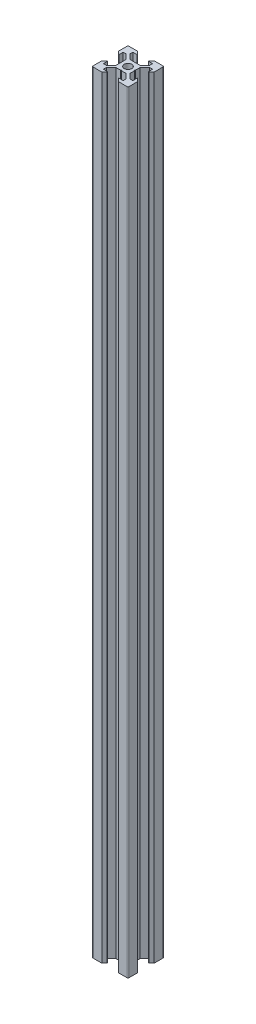
from build123d import *

# Parameters (mm, degrees)
SKETCH1_R           = 2.1
BOSS_EXTRUDE1_DEPTH = 430


with BuildPart() as part:
    # Sketch1 → Boss-Extrude1 (new body)
    with BuildSketch(Plane(origin=(0, -10, 0), x_dir=(1, 0, 0), z_dir=(0, 1, 0))):
        with BuildLine():
            Line((419, 554.5), (419, 549.58))
            Line((419, 549.58), (420.455, 548.125))
            Line((420.455, 548.125), (420.8, 548.125))
            Line((420.8, 548.125), (420.8, 550.5))
            Line((420.8, 550.5), (422.439339828, 550.5))
            Line((422.439339828, 550.5), (425.1, 547.839339828))
            Line((425.1, 547.839339828), (425.1, 545.21))
            Line((425.1, 545.21), (425.31, 545))
            Line((425.31, 545), (425.1, 544.79))
            Line((425.1, 544.79), (425.1, 542.160660172))
            Line((425.1, 542.160660172), (422.439339828, 539.5))
            Line((422.439339828, 539.5), (420.8, 539.5))
            Line((420.8, 539.5), (420.8, 541.875))
            Line((420.8, 541.875), (420.455, 541.875))
            Line((420.455, 541.875), (419, 540.42))
            Line((419, 540.42), (419, 535.5))
            ThreePointArc((419, 535.5), (419.146446609, 535.146446609), (419.5, 535))
            Line((419.5, 535), (424.42, 535))
            Line((424.42, 535), (425.875, 536.455))
            Line((425.875, 536.455), (425.875, 536.8))
            Line((425.875, 536.8), (423.5, 536.8))
            Line((423.5, 536.8), (423.5, 538.439339828))
            Line((423.5, 538.439339828), (426.160660172, 541.1))
            Line((426.160660172, 541.1), (428.79, 541.1))
            Line((428.79, 541.1), (429, 541.31))
            Line((429, 541.31), (429.21, 541.1))
            Line((429.21, 541.1), (431.839339828, 541.1))
            Line((431.839339828, 541.1), (434.5, 538.439339828))
            Line((434.5, 538.439339828), (434.5, 536.8))
            Line((434.5, 536.8), (432.125, 536.8))
            Line((432.125, 536.8), (432.125, 536.455))
            Line((432.125, 536.455), (433.58, 535))
            Line((433.58, 535), (438.5, 535))
            ThreePointArc((438.5, 535), (438.853553391, 535.146446609), (439, 535.5))
            Line((439, 535.5), (439, 540.42))
            Line((439, 540.42), (437.545, 541.875))
            Line((437.545, 541.875), (437.2, 541.875))
            Line((437.2, 541.875), (437.2, 539.5))
            Line((437.2, 539.5), (435.560660172, 539.5))
            Line((435.560660172, 539.5), (432.9, 542.160660172))
            Line((432.9, 542.160660172), (432.9, 544.79))
            Line((432.9, 544.79), (432.69, 545))
            Line((432.69, 545), (432.9, 545.21))
            Line((432.9, 545.21), (432.9, 547.839339829))
            Line((432.9, 547.839339829), (435.560660171, 550.5))
            Line((435.560660171, 550.5), (437.2, 550.5))
            Line((437.2, 550.5), (437.2, 548.125))
            Line((437.2, 548.125), (437.545, 548.125))
            Line((437.545, 548.125), (439, 549.58))
            Line((439, 549.58), (439, 554.5))
            ThreePointArc((439, 554.5), (438.853553391, 554.853553391), (438.5, 555))
            Line((438.5, 555), (433.58, 555))
            Line((433.58, 555), (432.125, 553.545))
            Line((432.125, 553.545), (432.125, 553.2))
            Line((432.125, 553.2), (434.5, 553.2))
            Line((434.5, 553.2), (434.5, 551.560660172))
            Line((434.5, 551.560660172), (431.839339828, 548.9))
            Line((431.839339828, 548.9), (429.21, 548.9))
            Line((429.21, 548.9), (429, 548.69))
            Line((429, 548.69), (428.79, 548.9))
            Line((428.79, 548.9), (426.160660172, 548.9))
            Line((426.160660172, 548.9), (423.5, 551.560660172))
            Line((423.5, 551.560660172), (423.5, 553.2))
            Line((423.5, 553.2), (425.875, 553.2))
            Line((425.875, 553.2), (425.875, 553.545))
            Line((425.875, 553.545), (424.42, 555))
            Line((424.42, 555), (419.5, 555))
            ThreePointArc((419.5, 555), (419.146446609, 554.853553391), (419, 554.5))
        make_face()
        with Locations((429, 545)):
            Circle(SKETCH1_R, mode=Mode.SUBTRACT)
    extrude(amount=-BOSS_EXTRUDE1_DEPTH)


solid = part.part
